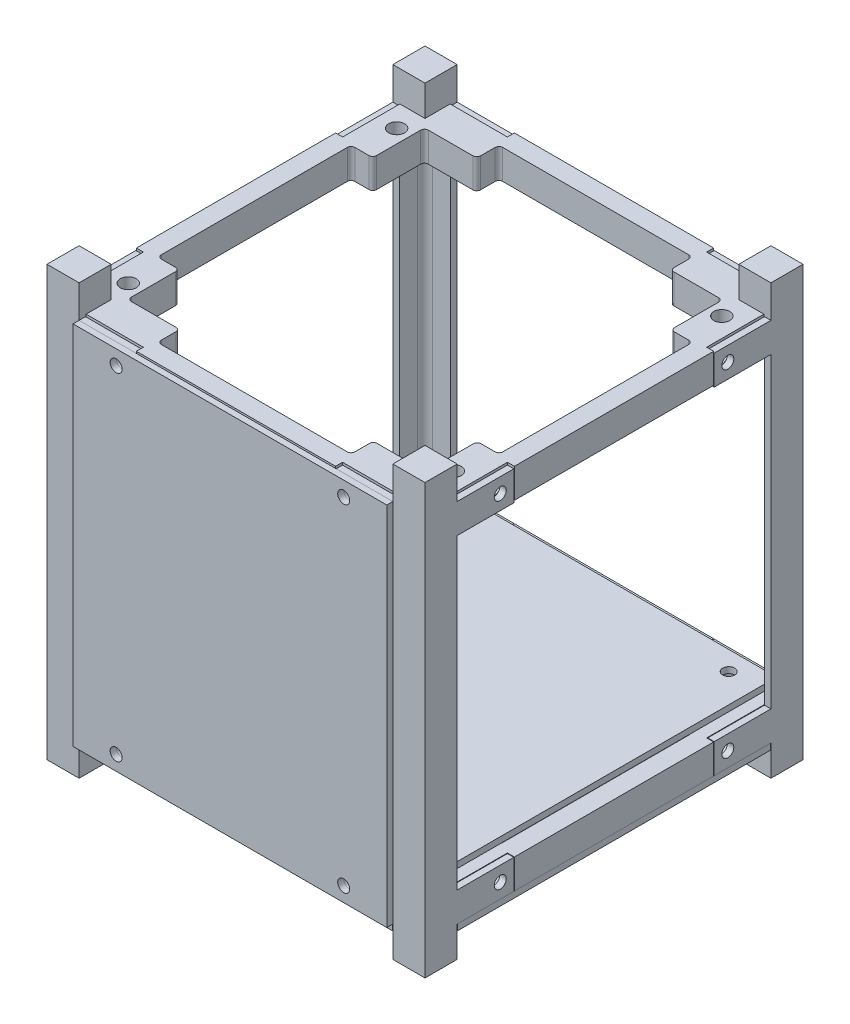
from build123d import *

# Parameters (mm, degrees)
SKETCH4_W            = 8.5
SKETCH4_H            = 8.5
BOSS_EXTRUDE2_DEPTH  = 8.1
BOSS_EXTRUDE3_START  = 8.1
BOSS_EXTRUDE3_DEPTH  = 96.8
BOSS_EXTRUDE4_START  = 104.9
SKETCH4_5_W          = 8.5
SKETCH4_5_H          = 8.5
BOSS_EXTRUDE4_DEPTH  = 8.6
SKETCH5_W            = 15
SKETCH5_H            = 7.8
BOSS_EXTRUDE5_DEPTH  = 1.7
SKETCH6_W            = 15
SKETCH6_H            = 7.8
BOSS_EXTRUDE6_DEPTH  = 1.7
BOSS_EXTRUDE7_START  = 8.1
SKETCH7_R            = 1.59
BOSS_EXTRUDE7_DEPTH  = 1.6
BOSS_EXTRUDE8_START  = 8.1
BOSS_EXTRUDE8_DEPTH  = 7.8
CUT_EXTRUDE9_START   = 8.1
SKETCH9_4_R          = 2.1
CUT_EXTRUDE9_DEPTH   = 5.8
SKETCH10_R           = 1.59
CUT_EXTRUDE1_DEPTH   = 160.31807807
CUT_EXTRUDE2_START   = -98.15
SKETCH10_3_R         = 2.1
CUT_EXTRUDE2_DEPTH   = 5.8
CUT_EXTRUDE10_START  = -1.85
SKETCH10_4_R         = 2.1
SKETCH10_4_R_2       = 1.59
CUT_EXTRUDE10_DEPTH  = 5.8
SKETCH11_R           = 1.59
CUT_EXTRUDE3_DEPTH   = 160.31807807
CUT_EXTRUDE4_START   = -1.85
SKETCH11_3_R         = 2.1
CUT_EXTRUDE4_DEPTH   = 5.8
SKETCH12_R           = 1.59
CUT_EXTRUDE5_DEPTH   = 1.7
CUT_EXTRUDE6_START   = -1.85
SKETCH12_3_R         = 2.1
CUT_EXTRUDE6_DEPTH   = 5.8
BOSS_EXTRUDE9_START  = 15.9
PUMPKIN_PCB_W        = 90.17
PUMPKIN_PCB_H        = 95.89
PUMPKIN_PCB_R        = 1.59
BOSS_EXTRUDE9_DEPTH  = 1.6
SKETCH14_W           = 15
SKETCH14_H           = 2
CUT_EXTRUDE7_DEPTH   = 1
CUT_EXTRUDE8_START   = 15.9
SKETCH9_3_R          = 2.1
SKETCH9_3_R_2        = 1.65
CUT_EXTRUDE8_DEPTH   = 5.8
CUT_EXTRUDE11_START  = 97.6
SKETCH9_5_R          = 1.65
CUT_EXTRUDE11_DEPTH  = 5.8
BOSS_EXTRUDE11_START = 50
SKETCH15_W           = 83
SKETCH15_H           = 96.8
SKETCH15_R           = 1.59
BOSS_EXTRUDE11_DEPTH = 1.6


with BuildPart() as part:
    # Sketch4 → Boss-Extrude2 (new body)
    with BuildSketch(Plane(origin=(0, 0, 0), x_dir=(1, 0, 0), z_dir=(0, 1, 0))):
        with Locations((-45.75, 45.75)):
            Rectangle(SKETCH4_W, SKETCH4_H)
    extrude(amount=BOSS_EXTRUDE2_DEPTH)

    # Sketch4_4 → Boss-Extrude3 (add)
    with BuildSketch(Plane(origin=(0, 0, 0), x_dir=(1, 0, 0), z_dir=(0, 1, 0)).offset(BOSS_EXTRUDE3_START)):
        with BuildLine():
            Line((-50, 41.5), (-48.3, 41.5))
            Line((-48.3, 41.5), (-48.3, 46.3))
            ThreePointArc((-48.3, 46.3), (-47.714213562, 47.714213562), (-46.3, 48.3))
            Line((-46.3, 48.3), (-41.5, 48.3))
            Line((-41.5, 48.3), (-41.5, 50))
            Line((-41.5, 50), (-50, 50))
            Line((-50, 50), (-50, 41.5))
        make_face()
    extrude(amount=BOSS_EXTRUDE3_DEPTH)

    # Sketch4_5 → Boss-Extrude4 (add)
    with BuildSketch(Plane(origin=(0, 0, 0), x_dir=(1, 0, 0), z_dir=(0, 1, 0)).offset(BOSS_EXTRUDE4_START)):
        with Locations((-45.75, 45.75)):
            Rectangle(SKETCH4_5_W, SKETCH4_5_H)
    extrude(amount=BOSS_EXTRUDE4_DEPTH)

    # Sketch5 → Boss-Extrude5 (add)
    with BuildSketch(Plane.ZY.offset(50)):
        with Locations((-34, 12)):
            Rectangle(SKETCH5_W, SKETCH5_H)
        with Locations((-34, 101)):
            Rectangle(SKETCH5_W, SKETCH5_H)
    extrude(amount=-BOSS_EXTRUDE5_DEPTH)

    # Sketch6 → Boss-Extrude6 (add)
    with BuildSketch(Plane.XY.offset(-50)):
        with Locations((-34, 101)):
            Rectangle(SKETCH6_W, SKETCH6_H)
        with Locations((-34, 12)):
            Rectangle(SKETCH6_W, SKETCH6_H)
    extrude(amount=BOSS_EXTRUDE6_DEPTH)


with BuildPart() as body_2:
    # Sketch7 → Boss-Extrude7 (new body)
    with BuildSketch(Plane(origin=(0, 0, 0), x_dir=(1, 0, 0), z_dir=(0, 1, 0)).offset(BOSS_EXTRUDE7_START)):
        Polygon((-50, 41.35), (-50, -41.35), (-41.35, -41.35), (-41.35, -50), (41.35, -50), (41.35, -41.35), (50, -41.35), (50, 41.35), (41.35, 41.35), (41.35, 50), (-41.35, 50), (-41.35, 41.35), align=None)
        with Locations(Location((-43, 35.5, 0), (0, 0, 270))):
            Circle(SKETCH7_R, mode=Mode.SUBTRACT)
        with Locations(Location((43, 35.5, 0), (0, 0, 270))):
            Circle(SKETCH7_R, mode=Mode.SUBTRACT)
        with Locations(Location((43, -35.5, 0), (0, 0, 270))):
            Circle(SKETCH7_R, mode=Mode.SUBTRACT)
        with Locations(Location((-43, -35.5, 0), (0, 0, 270))):
            Circle(SKETCH7_R, mode=Mode.SUBTRACT)
    extrude(amount=-BOSS_EXTRUDE7_DEPTH)


with BuildPart() as body_3:
    # Sketch9 → Boss-Extrude8 (new body)
    with BuildSketch(Plane(origin=(0, 0, 0), x_dir=(1, 0, 0), z_dir=(0, 1, 0)).offset(BOSS_EXTRUDE8_START)):
        with BuildLine():
            ThreePointArc((-46.3, 48.15), (-47.608147545, 47.608147545), (-48.15, 46.3))
            Line((-48.15, 46.3), (-48.15, 26.35))
            Line((-48.15, 26.35), (-50, 26.35))
            Line((-50, 26.35), (-50, -26.35))
            Line((-50, -26.35), (-48.15, -26.35))
            Line((-48.15, -26.35), (-48.15, -46.3))
            ThreePointArc((-48.15, -46.3), (-47.608147545, -47.608147545), (-46.3, -48.15))
            Line((-46.3, -48.15), (-26.35, -48.15))
            Line((-26.35, -48.15), (-26.35, -50))
            Line((-26.35, -50), (26.35, -50))
            Line((26.35, -50), (26.35, -48.15))
            Line((26.35, -48.15), (46.3, -48.15))
            ThreePointArc((46.3, -48.15), (47.608147545, -47.608147545), (48.15, -46.3))
            Line((48.15, -46.3), (48.15, -26.35))
            Line((48.15, -26.35), (50, -26.35))
            Line((50, -26.35), (50, 26.35))
            Line((50, 26.35), (48.15, 26.35))
            Line((48.15, 26.35), (48.15, 46.3))
            ThreePointArc((48.15, 46.3), (47.608147545, 47.608147545), (46.3, 48.15))
            Line((46.3, 48.15), (26.35, 48.15))
            Line((26.35, 48.15), (26.35, 50))
            Line((26.35, 50), (-26.35, 50))
            Line((-26.35, 50), (-26.35, 48.15))
            Line((-26.35, 48.15), (-46.3, 48.15))
        make_face()
        with BuildLine():
            ThreePointArc((-45.15, 24.595), (-44.857106781, 25.302106781), (-44.15, 25.595))
            Line((-44.15, 25.595), (-40.41, 25.595))
            ThreePointArc((-40.41, 25.595), (-39.702893219, 25.887893219), (-39.41, 26.595))
            Line((-39.41, 26.595), (-39.41, 38.275))
            ThreePointArc((-39.41, 38.275), (-39.117106781, 38.982106781), (-38.41, 39.275))
            Line((-38.41, 39.275), (-26.595, 39.275))
            ThreePointArc((-26.595, 39.275), (-25.887893219, 39.567893219), (-25.595, 40.275))
            Line((-25.595, 40.275), (-25.595, 44.15))
            ThreePointArc((-25.595, 44.15), (-25.302106781, 44.857106781), (-24.595, 45.15))
            Line((-24.595, 45.15), (24.595, 45.15))
            ThreePointArc((24.595, 45.15), (25.302106781, 44.857106781), (25.595, 44.15))
            Line((25.595, 44.15), (25.595, 40.275))
            ThreePointArc((25.595, 40.275), (25.887893219, 39.567893219), (26.595, 39.275))
            Line((26.595, 39.275), (38.41, 39.275))
            ThreePointArc((38.41, 39.275), (39.117106781, 38.982106781), (39.41, 38.275))
            Line((39.41, 38.275), (39.41, 26.595))
            ThreePointArc((39.41, 26.595), (39.702893219, 25.887893219), (40.41, 25.595))
            Line((40.41, 25.595), (44.15, 25.595))
            ThreePointArc((44.15, 25.595), (44.857106781, 25.302106781), (45.15, 24.595))
            Line((45.15, 24.595), (45.15, -24.595))
            ThreePointArc((45.15, -24.595), (44.857106781, -25.302106781), (44.15, -25.595))
            Line((44.15, -25.595), (40.41, -25.595))
            ThreePointArc((40.41, -25.595), (39.702893219, -25.887893219), (39.41, -26.595))
            Line((39.41, -26.595), (39.41, -38.275))
            ThreePointArc((39.41, -38.275), (39.117106781, -38.982106781), (38.41, -39.275))
            Line((38.41, -39.275), (26.595, -39.275))
            ThreePointArc((26.595, -39.275), (25.887893219, -39.567893219), (25.595, -40.275))
            Line((25.595, -40.275), (25.595, -44.15))
            ThreePointArc((25.595, -44.15), (25.302106781, -44.857106781), (24.595, -45.15))
            Line((24.595, -45.15), (-24.595, -45.15))
            ThreePointArc((-24.595, -45.15), (-25.302106781, -44.857106781), (-25.595, -44.15))
            Line((-25.595, -44.15), (-25.595, -40.275))
            ThreePointArc((-25.595, -40.275), (-25.887893219, -39.567893219), (-26.595, -39.275))
            Line((-26.595, -39.275), (-38.41, -39.275))
            ThreePointArc((-38.41, -39.275), (-39.117106781, -38.982106781), (-39.41, -38.275))
            Line((-39.41, -38.275), (-39.41, -26.595))
            ThreePointArc((-39.41, -26.595), (-39.702893219, -25.887893219), (-40.41, -25.595))
            Line((-40.41, -25.595), (-44.15, -25.595))
            ThreePointArc((-44.15, -25.595), (-44.857106781, -25.302106781), (-45.15, -24.595))
            Line((-45.15, -24.595), (-45.15, 24.595))
        make_face(mode=Mode.SUBTRACT)
    extrude(amount=BOSS_EXTRUDE8_DEPTH)

    # Sketch9_4 → Cut-Extrude9 (cut)
    with BuildSketch(Plane(origin=(0, 0, 0), x_dir=(1, 0, 0), z_dir=(0, 1, 0)).offset(CUT_EXTRUDE9_START)):
        with Locations(Location((-43, -35.5, 0), (0, 0, 270))):
            Circle(SKETCH9_4_R)
        with Locations(Location((-43, 35.5, 0), (0, 0, 270))):
            Circle(SKETCH9_4_R)
        with Locations(Location((43, 35.5, 0), (0, 0, 270))):
            Circle(SKETCH9_4_R)
        with Locations(Location((43, -35.5, 0), (0, 0, 270))):
            Circle(SKETCH9_4_R)
    extrude(amount=CUT_EXTRUDE9_DEPTH, mode=Mode.SUBTRACT)

    # Sketch10_3 → Cut-Extrude2 (cut)
    with BuildSketch(Plane.ZY.offset(50).offset(CUT_EXTRUDE2_START)):
        with Locations((-30.095, 12)):
            Circle(SKETCH10_3_R)
        with Locations((30.095, 12)):
            Circle(SKETCH10_3_R)
    extrude(amount=CUT_EXTRUDE2_DEPTH, mode=Mode.SUBTRACT)

    # Sketch10_4 → Cut-Extrude10 (cut)
    with BuildSketch(Plane.ZY.offset(50).offset(CUT_EXTRUDE10_START)):
        with Locations((-30.095, 12)):
            Circle(SKETCH10_4_R)
        with Locations((-30.095, 12)):
            Circle(SKETCH10_4_R_2, mode=Mode.SUBTRACT)
        with Locations((-30.095, 12)):
            Circle(SKETCH10_4_R_2)
        with Locations((30.095, 12)):
            Circle(SKETCH10_4_R)
        with Locations((30.095, 12)):
            Circle(SKETCH10_4_R_2, mode=Mode.SUBTRACT)
        with Locations((30.095, 12)):
            Circle(SKETCH10_4_R_2)
    extrude(amount=-CUT_EXTRUDE10_DEPTH, mode=Mode.SUBTRACT)

    # Sketch11_3 → Cut-Extrude4 (cut)
    with BuildSketch(Plane(origin=(0, 0, -50), x_dir=(-1, 0, 0), z_dir=(0, 0, -1)).offset(CUT_EXTRUDE4_START)):
        with Locations(Location((30.095, 12, 0), (0, 0, 180))):
            Circle(SKETCH11_3_R)
        with Locations(Location((-30.095, 12, 0), (0, 0, 180))):
            Circle(SKETCH11_3_R)
    extrude(amount=-CUT_EXTRUDE4_DEPTH, mode=Mode.SUBTRACT)

    # Sketch12_3 → Cut-Extrude6 (cut)
    with BuildSketch(Plane.XY.offset(50).offset(CUT_EXTRUDE6_START)):
        with Locations((-30.095, 12)):
            Circle(SKETCH12_3_R)
        with Locations((30.095, 12)):
            Circle(SKETCH12_3_R)
    extrude(amount=-CUT_EXTRUDE6_DEPTH, mode=Mode.SUBTRACT)

    # Sketch14 → Cut-Extrude7 (cut)
    with BuildSketch(Plane(origin=(0, 15.9, 0), x_dir=(1, 0, 0), z_dir=(0, 1, 0))):
        with Locations((0, 47.575)):
            Rectangle(SKETCH14_W, SKETCH14_H)
    extrude(amount=-CUT_EXTRUDE7_DEPTH, mode=Mode.SUBTRACT)


with BuildPart() as body_4:
    # Mirror3: mirrored copy
    add(part.part.mirror(Plane(origin=(0, 0, 0), x_dir=(0, 0, 1), z_dir=(1, 0, 0))))


with BuildPart() as body_5:
    # Mirror4: mirrored copy
    add(part.part.mirror(Plane.XY))


with BuildPart() as body_6:
    # Mirror4 2: mirrored copy
    add(body_4.part.mirror(Plane.XY))


with BuildPart() as cut_extrude1_tool:
    # Sketch10 → Cut-Extrude1 (new, through all)
    with BuildSketch(Plane.ZY.offset(50)):
        with Locations((-30.095, 101)):
            Circle(SKETCH10_R)
        with Locations((30.095, 101)):
            Circle(SKETCH10_R)
        with Locations((30.095, 12)):
            Circle(SKETCH10_R)
        with Locations((-30.095, 12)):
            Circle(SKETCH10_R)
    extrude(amount=-CUT_EXTRUDE1_DEPTH)


with BuildPart() as part_1:
    add(part.part)

    # Cut-Extrude1: cut by cut_extrude1_tool
    add(cut_extrude1_tool.part, mode=Mode.SUBTRACT)


with BuildPart() as body_5_1:
    add(body_5.part)

    # Cut-Extrude1: cut by cut_extrude1_tool
    add(cut_extrude1_tool.part, mode=Mode.SUBTRACT)


with BuildPart() as body_6_1:
    add(body_6.part)

    # Cut-Extrude1: cut by cut_extrude1_tool
    add(cut_extrude1_tool.part, mode=Mode.SUBTRACT)


with BuildPart() as body_4_1:
    add(body_4.part)

    # Cut-Extrude1: cut by cut_extrude1_tool
    add(cut_extrude1_tool.part, mode=Mode.SUBTRACT)


with BuildPart() as cut_extrude3_tool:
    # Sketch11 → Cut-Extrude3 (new, through all)
    with BuildSketch(Plane(origin=(0, 0, -50), x_dir=(-1, 0, 0), z_dir=(0, 0, -1))):
        with Locations((30.095, 12)):
            Circle(SKETCH11_R)
        with Locations(Location((30.095, 101, 0), (0, 0, 180))):
            Circle(SKETCH11_R)
        with Locations((-30.095, 12)):
            Circle(SKETCH11_R)
        with Locations(Location((-30.095, 101, 0), (0, 0, 180))):
            Circle(SKETCH11_R)
    extrude(amount=-CUT_EXTRUDE3_DEPTH)


with BuildPart() as body_4_2:
    add(body_4_1.part)

    # Cut-Extrude3: cut by cut_extrude3_tool
    add(cut_extrude3_tool.part, mode=Mode.SUBTRACT)


with BuildPart() as part_2:
    add(part_1.part)

    # Cut-Extrude3: cut by cut_extrude3_tool
    add(cut_extrude3_tool.part, mode=Mode.SUBTRACT)


with BuildPart() as cut_extrude5_tool:
    # Sketch12 → Cut-Extrude5 (new body)
    with BuildSketch(Plane.XY.offset(50)):
        with Locations((-30.095, 12)):
            Circle(SKETCH12_R)
        with Locations(Location((30.095, 12, 0), (0, 0, 180))):
            Circle(SKETCH12_R)
        with Locations((-30.095, 101)):
            Circle(SKETCH12_R)
        with Locations((30.095, 101)):
            Circle(SKETCH12_R)
    extrude(amount=-CUT_EXTRUDE5_DEPTH)


with BuildPart() as body_5_2:
    add(body_5_1.part)

    # Cut-Extrude5: cut by cut_extrude5_tool
    add(cut_extrude5_tool.part, mode=Mode.SUBTRACT)


with BuildPart() as body_6_2:
    add(body_6_1.part)

    # Cut-Extrude5: cut by cut_extrude5_tool
    add(cut_extrude5_tool.part, mode=Mode.SUBTRACT)


with BuildPart() as body_7:
    # Pumpkin_PCB → Boss-Extrude9 (new body)
    with BuildSketch(Plane(origin=(0, 0, 0), x_dir=(1, 0, 0), z_dir=(0, 1, 0)).offset(BOSS_EXTRUDE9_START)):
        Rectangle(PUMPKIN_PCB_W, PUMPKIN_PCB_H)
        with Locations(Location((40.005, -42.865, 0), (0, 0, 270))):
            Circle(PUMPKIN_PCB_R, mode=Mode.SUBTRACT)
        with Locations(Location((37.465, 42.865, 0), (0, 0, 270))):
            Circle(PUMPKIN_PCB_R, mode=Mode.SUBTRACT)
        with Locations(Location((-40.005, -42.865, 0), (0, 0, 270))):
            Circle(PUMPKIN_PCB_R, mode=Mode.SUBTRACT)
        with Locations(Location((-36.195, 42.865, 0), (0, 0, 270))):
            Circle(PUMPKIN_PCB_R, mode=Mode.SUBTRACT)
    extrude(amount=BOSS_EXTRUDE9_DEPTH)


with BuildPart() as body_8:
    # Mirror5: mirrored copy
    add(body_3.part.mirror(Plane.ZX.offset(56.75)))

    # Sketch9_5 → Cut-Extrude11 (cut)
    with BuildSketch(Plane(origin=(0, 0, 0), x_dir=(1, 0, 0), z_dir=(0, 1, 0)).offset(CUT_EXTRUDE11_START)):
        with Locations(Location((-40.005, -42.865, 0), (0, 0, 90))):
            Circle(SKETCH9_5_R)
        with Locations(Location((40.005, -42.865, 0), (0, 0, 90))):
            Circle(SKETCH9_5_R)
        with Locations(Location((37.465, 42.865, 0), (0, 0, 90))):
            Circle(SKETCH9_5_R)
        with Locations(Location((-36.195, 42.865, 0), (0, 0, 90))):
            Circle(SKETCH9_5_R)
    extrude(amount=CUT_EXTRUDE11_DEPTH, mode=Mode.SUBTRACT)


with BuildPart() as body_3_1:
    add(body_3.part)

    # Sketch9_3 → Cut-Extrude8 (cut)
    with BuildSketch(Plane(origin=(0, 0, 0), x_dir=(1, 0, 0), z_dir=(0, 1, 0)).offset(CUT_EXTRUDE8_START)):
        with Locations(Location((-36.195, 42.865, 0), (0, 0, 270))):
            Circle(SKETCH9_3_R)
        with Locations(Location((-40.005, -42.865, 0), (0, 0, 270))):
            Circle(SKETCH9_3_R)
        with Locations((-40.005, -42.865)):
            Circle(SKETCH9_3_R_2, mode=Mode.SUBTRACT)
        with Locations((-40.005, -42.865)):
            Circle(SKETCH9_3_R_2)
        with Locations(Location((40.005, -42.865, 0), (0, 0, 270))):
            Circle(SKETCH9_3_R)
        with Locations((40.005, -42.865)):
            Circle(SKETCH9_3_R_2, mode=Mode.SUBTRACT)
        with Locations((40.005, -42.865)):
            Circle(SKETCH9_3_R_2)
        with Locations(Location((37.465, 42.865, 0), (0, 0, 270))):
            Circle(SKETCH9_3_R)
        with Locations((37.465, 42.865)):
            Circle(SKETCH9_3_R_2, mode=Mode.SUBTRACT)
        with Locations((37.465, 42.865)):
            Circle(SKETCH9_3_R_2)
        with Locations((-36.195, 42.865)):
            Circle(SKETCH9_3_R_2)
    extrude(amount=-CUT_EXTRUDE8_DEPTH, mode=Mode.SUBTRACT)


with BuildPart() as body_9:
    # Sketch15 → Boss-Extrude11 (new body)
    with BuildSketch(Plane.XY.offset(BOSS_EXTRUDE11_START)):
        with Locations((0, 56.5)):
            Rectangle(SKETCH15_W, SKETCH15_H)
        with Locations(Location((30.095, 12, 0), (0, 0, 180))):
            Circle(SKETCH15_R, mode=Mode.SUBTRACT)
        with Locations((30.095, 101)):
            Circle(SKETCH15_R, mode=Mode.SUBTRACT)
        with Locations((-30.095, 12)):
            Circle(SKETCH15_R, mode=Mode.SUBTRACT)
        with Locations((-30.095, 101)):
            Circle(SKETCH15_R, mode=Mode.SUBTRACT)
    extrude(amount=BOSS_EXTRUDE11_DEPTH)


solid = Compound([body_2.part, body_4_2.part, part_2.part, body_5_2.part, body_6_2.part, body_7.part, body_8.part, body_3_1.part, body_9.part])
